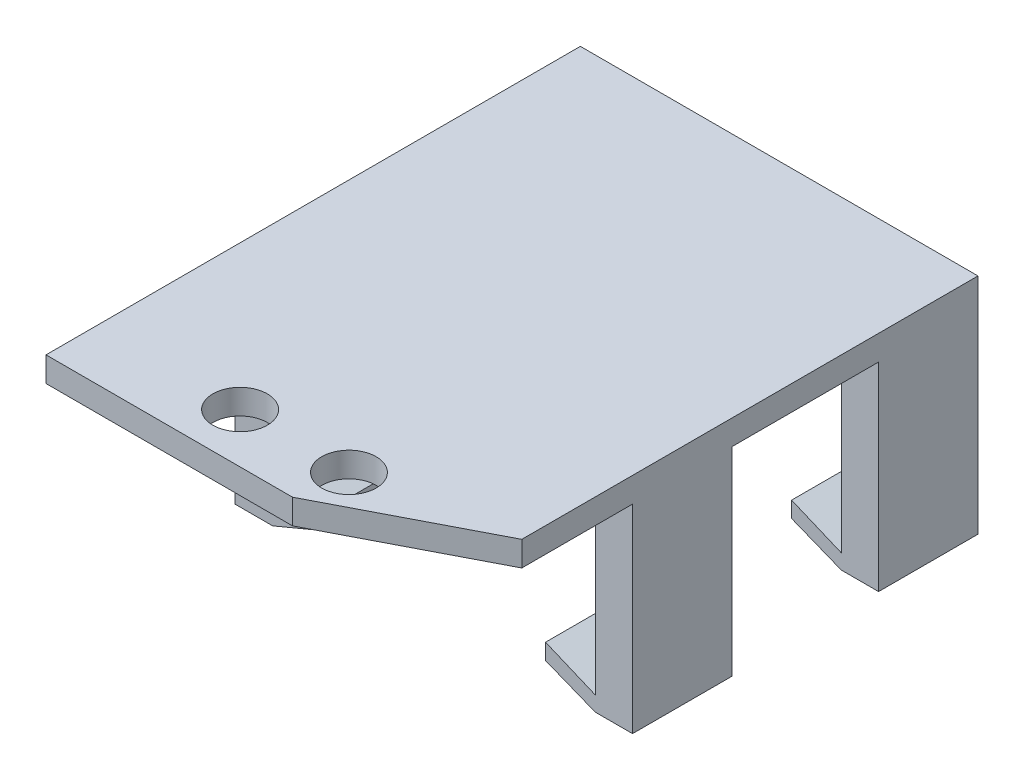
from build123d import *

# Parameters (mm, degrees)
SKETCH3_R           = 2.7813
BOSS_EXTRUDE3_DEPTH = 2.54
SKETCH4_W           = 3.81
SKETCH4_H           = 40.386
BOSS_EXTRUDE4_DEPTH = 20.32
SKETCH5_W           = 40.386
SKETCH5_H           = 1.524
BOSS_EXTRUDE5_DEPTH = 5.08
SKETCH6_W           = 40.386
SKETCH6_H           = 1.524
BOSS_EXTRUDE6_DEPTH = 5.08
SKETCH7_W           = 40.64
SKETCH7_H           = 20.32
CUT_EXTRUDE1_DEPTH  = 5.08
SKETCH11_W          = 40.64
SKETCH11_H          = 35.306
BOSS_EXTRUDE7_DEPTH = 2.9718
BOSS_EXTRUDE8_DEPTH = 35.306
SKETCH8_W           = 14.986
SKETCH8_H           = 20.32
CUT_EXTRUDE2_DEPTH  = 41.64
CUT_EXTRUDE3_DEPTH  = 36.306
SKETCH14_R          = 3.81
SKETCH14_R_2        = 2.7813
BOSS_EXTRUDE9_DEPTH = 2.54
CUT_EXTRUDE4_DEPTH  = 23.86


with BuildPart() as part:
    # Sketch3 → Boss-Extrude3 (new body)
    with BuildSketch(Plane(origin=(0, 0, 0), x_dir=(1, 0, 0), z_dir=(0, 1, 0))):
        Polygon((-11.517251908, 12.440983784), (29.122748092, 12.440983784), (29.122748092, -34.564151764), (29.122748092, -42.169016216), (18.885256114, -42.169016216), (-11.517251908, -42.169016216), align=None)
        with Locations((3.240148092, -37.089016216)):
            Circle(SKETCH3_R, mode=Mode.SUBTRACT)
        with Locations((14.365348092, -37.089016216)):
            Circle(SKETCH3_R, mode=Mode.SUBTRACT)
    extrude(amount=BOSS_EXTRUDE3_DEPTH)

    # Sketch4 → Boss-Extrude4 (add)
    with BuildSketch(Plane.XZ):
        with Locations((-9.612251908, 7.752016216)):
            Rectangle(SKETCH4_W, SKETCH4_H)
        with Locations((27.217748092, 7.752016216)):
            Rectangle(SKETCH4_W, SKETCH4_H)
    extrude(amount=BOSS_EXTRUDE4_DEPTH)

    # Sketch5 → Boss-Extrude5 (add)
    with BuildSketch(Plane(origin=(-7.707251908, 0, 0), x_dir=(0, 0, -1), z_dir=(1, 0, 0))):
        with Locations((-7.752016216, -19.558)):
            Rectangle(SKETCH5_W, SKETCH5_H)
    extrude(amount=BOSS_EXTRUDE5_DEPTH)

    # Sketch6 → Boss-Extrude6 (add)
    with BuildSketch(Plane.ZY.offset(-25.312748092)):
        with Locations((7.752016216, -19.558)):
            Rectangle(SKETCH6_W, SKETCH6_H)
    extrude(amount=BOSS_EXTRUDE6_DEPTH)

    # Sketch7 → Cut-Extrude1 (cut)
    with BuildSketch(Plane.XY.offset(27.945016216)):
        with Locations((8.802748092, -10.16)):
            Rectangle(SKETCH7_W, SKETCH7_H)
    extrude(amount=-CUT_EXTRUDE1_DEPTH, mode=Mode.SUBTRACT)

    # Sketch11 → Boss-Extrude7 (add)
    with BuildSketch(Plane.XZ):
        with Locations((8.802748092, 5.212016216)):
            Rectangle(SKETCH11_W, SKETCH11_H)
    extrude(amount=BOSS_EXTRUDE7_DEPTH)

    # Sketch12 → Boss-Extrude8 (add)
    with BuildSketch(Plane.XY.offset(22.865016216)):
        Polygon((-7.707251908, -18.796), (-2.593407451, -16.66881978), (-2.627251908, -18.796), align=None)
        Polygon((20.232748092, -18.796), (20.232748092, -16.66881978), (25.312748092, -18.796), align=None)
    extrude(amount=-BOSS_EXTRUDE8_DEPTH)

    # Sketch8 → Cut-Extrude2 (cut, through all)
    with BuildSketch(Plane(origin=(29.122748092, 0, 0), x_dir=(0, 0, -1), z_dir=(1, 0, 0))):
        with Locations((-5.212016216, -10.16)):
            Rectangle(SKETCH8_W, SKETCH8_H)
    extrude(amount=-CUT_EXTRUDE2_DEPTH, mode=Mode.SUBTRACT)

    # Sketch13 → Cut-Extrude3 (cut, through all)
    with BuildSketch(Plane.XY.offset(22.865016216)):
        Polygon((-2.618031664, -18.216492377), (-7.660745747, -20.32), (-2.627251908, -20.32), (-2.627251908, -18.796), align=None)
        Polygon((20.232748092, -18.294602636), (20.232748092, -20.32), (25.312748092, -20.32), align=None)
    extrude(amount=-CUT_EXTRUDE3_DEPTH, mode=Mode.SUBTRACT)

    # Sketch14 → Boss-Extrude9 (add)
    with BuildSketch(Plane.XZ):
        with Locations((3.240148092, 37.089016216)):
            Circle(SKETCH14_R)
        with Locations((3.240148092, 37.089016216)):
            Circle(SKETCH14_R_2, mode=Mode.SUBTRACT)
        with Locations((14.365348092, 37.089016216)):
            Circle(SKETCH14_R)
        with Locations((14.365348092, 37.089016216)):
            Circle(SKETCH14_R_2, mode=Mode.SUBTRACT)
    extrude(amount=-BOSS_EXTRUDE9_DEPTH)

    # Sketch15 → Cut-Extrude4 (cut, through all)
    with BuildSketch(Plane(origin=(0, 2.54, 0), x_dir=(1, 0, 0), z_dir=(0, 1, 0))):
        Polygon((18.885256114, -39.476616216), (13.678256114, -42.169016216), (29.122748092, -42.169016216), (29.122748092, -34.183083779), align=None)
    extrude(amount=-CUT_EXTRUDE4_DEPTH, mode=Mode.SUBTRACT)


solid = part.part
